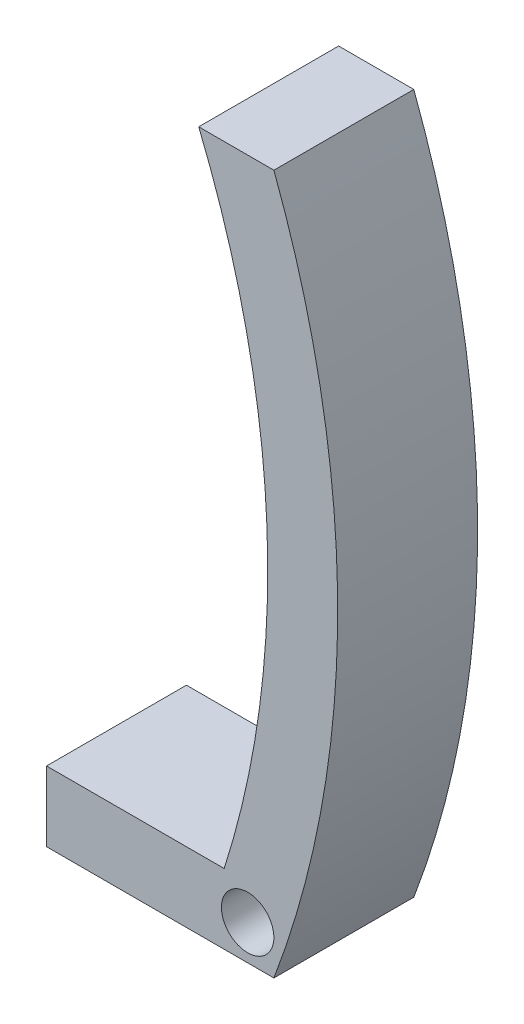
from build123d import *

# Parameters (mm, degrees)
BOSS_EXTRUDE1_DEPTH     = 10.16
SKETCH2_R               = 1.905
CUT_EXTRUDE1_DEPTH      = 1
CUT_EXTRUDE1_DEPTH_BACK = 11.16


with BuildPart() as part:
    # Sketch1 → Boss-Extrude1 (new body)
    with BuildSketch(Plane.XY):
        with BuildLine():
            Line((0, 0), (16.51, 0))
            ThreePointArc((16.51, 0), (21.143005914, 25.4), (16.51, 50.8))
            Line((16.51, 50.8), (11.050639123, 50.8))
            ThreePointArc((11.050639123, 50.8), (16.008340976, 28.103171462), (12.900542854, 5.08))
            Line((12.900542854, 5.08), (0, 5.08))
            Line((0, 5.08), (0, 0))
        make_face()
    extrude(amount=BOSS_EXTRUDE1_DEPTH)

    # Sketch2 → Cut-Extrude1 (cut, two sides)
    with BuildSketch(Plane.XY.offset(10.16)) as cut_extrude1_sk:
        with Locations((14.605, 2.54)):
            Circle(SKETCH2_R)
    extrude(amount=CUT_EXTRUDE1_DEPTH, mode=Mode.SUBTRACT)
    extrude(cut_extrude1_sk.sketch, amount=-CUT_EXTRUDE1_DEPTH_BACK, mode=Mode.SUBTRACT)


solid = part.part
